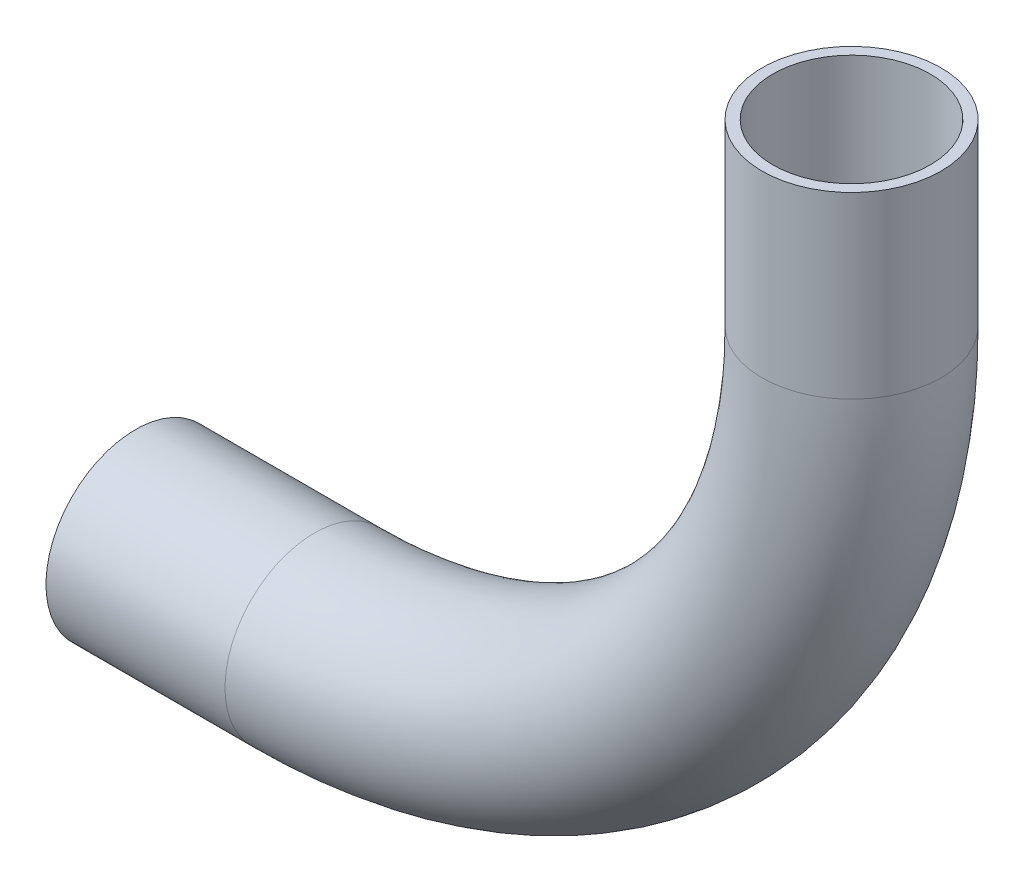
from build123d import *

# Parameters (mm, degrees)
SKETCH2_R   = 6.35
SKETCH2_R_2 = 5.588


with BuildPart() as part:
    # Sweep1: sweep along a path in Sketch1
    with BuildLine(Plane.XY) as sweep1_path:
        Line((51.128898203, 36.350052075), (51.128898203, 23.650052075))
        ThreePointArc((51.128898203, 23.650052075), (39.969666566, -3.290716288), (13.028898203, -14.449947925))
        Line((13.028898203, -14.449947925), (0.328898203, -14.449947925))
    # Sketch2 → Sweep1 (sweep)
    with BuildSketch(Plane(origin=(51.128898203, 36.350052075, 0), x_dir=(0, 0, -1), z_dir=(0, -1, 0))):
        Circle(SKETCH2_R)
        Circle(SKETCH2_R_2, mode=Mode.SUBTRACT)
    sweep(path=sweep1_path.line)


solid = part.part
